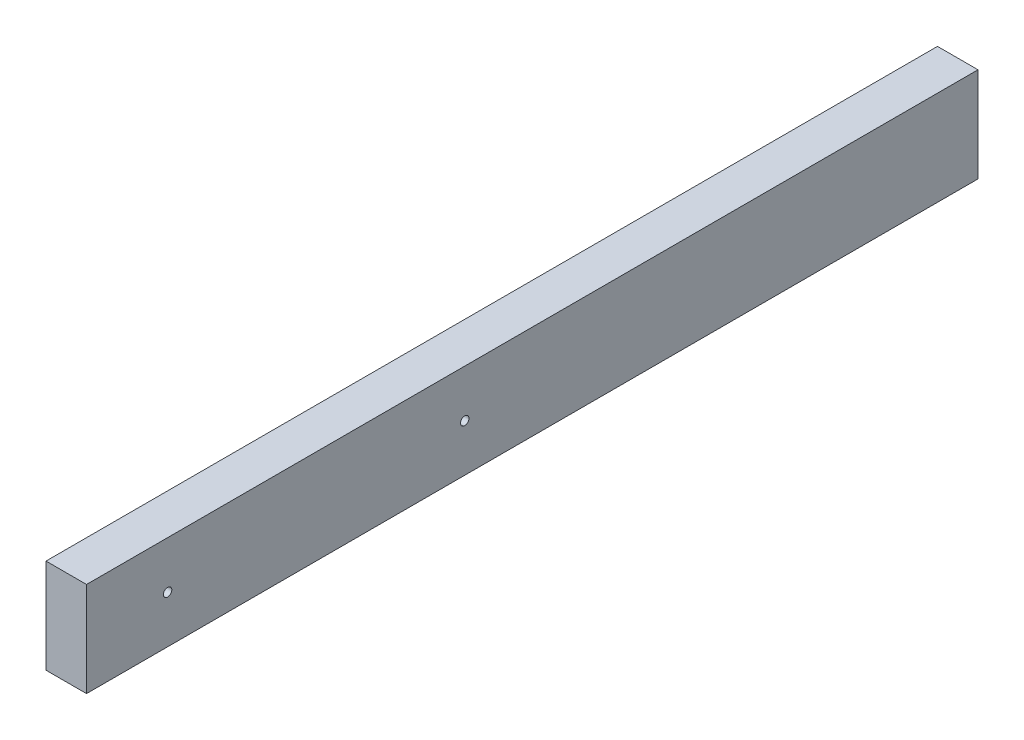
from build123d import *

# Parameters (mm, degrees)
SKETCH1_W                      = 38.1
SKETCH1_H                      = 88.9
BOSS_EXTRUDE1_DEPTH            = 838.2
F_5_16_0_3125_DIAMETER_HOLE1_D = 7.9375


with BuildPart() as part:
    # Sketch1 → Boss-Extrude1 (new body)
    with BuildSketch(Plane.XY):
        Rectangle(SKETCH1_W, SKETCH1_H)
    extrude(amount=BOSS_EXTRUDE1_DEPTH)

    # 5/16 (0.3125) Diameter Hole1 (through all)
    with Locations(Plane(origin=(19.05, 0, 0), x_dir=(0, 0, -1), z_dir=(1, 0, 0))):
        with Locations((-482.6, 0), (-762, 0)):
            Hole(F_5_16_0_3125_DIAMETER_HOLE1_D / 2)


solid = part.part
